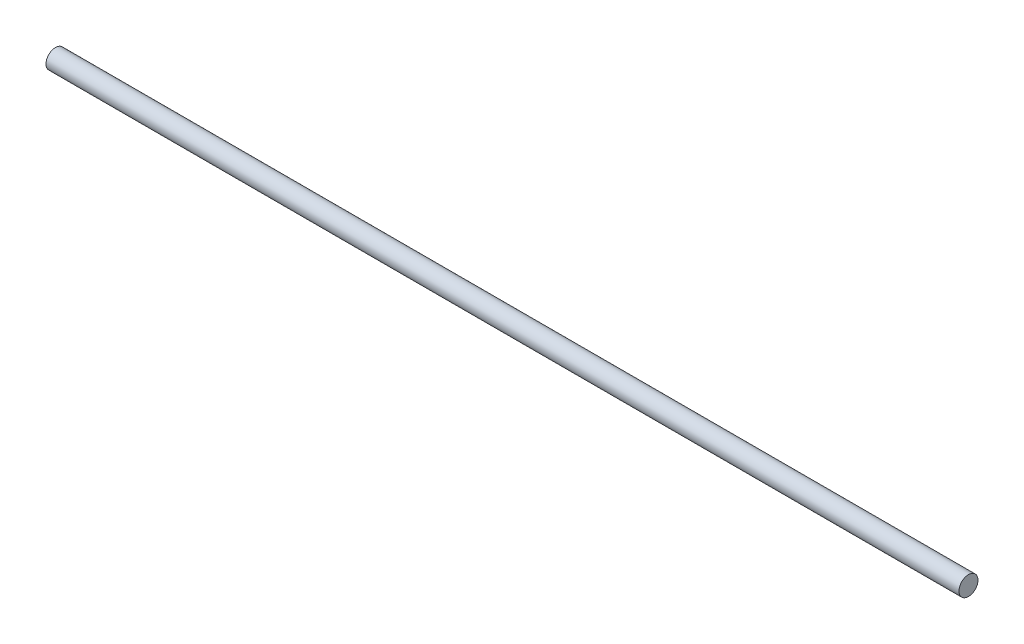
from build123d import *

# Parameters (mm, degrees)
SKETCH1_R           = 5
BOSS_EXTRUDE1_DEPTH = 240


with BuildPart() as part:
    # Sketch1 → Boss-Extrude1 (new body, symmetric)
    with BuildSketch(Plane(origin=(0, 0, 0), x_dir=(0, 0, -1), z_dir=(1, 0, 0))):
        Circle(SKETCH1_R)
    extrude(amount=BOSS_EXTRUDE1_DEPTH, both=True)


solid = part.part
